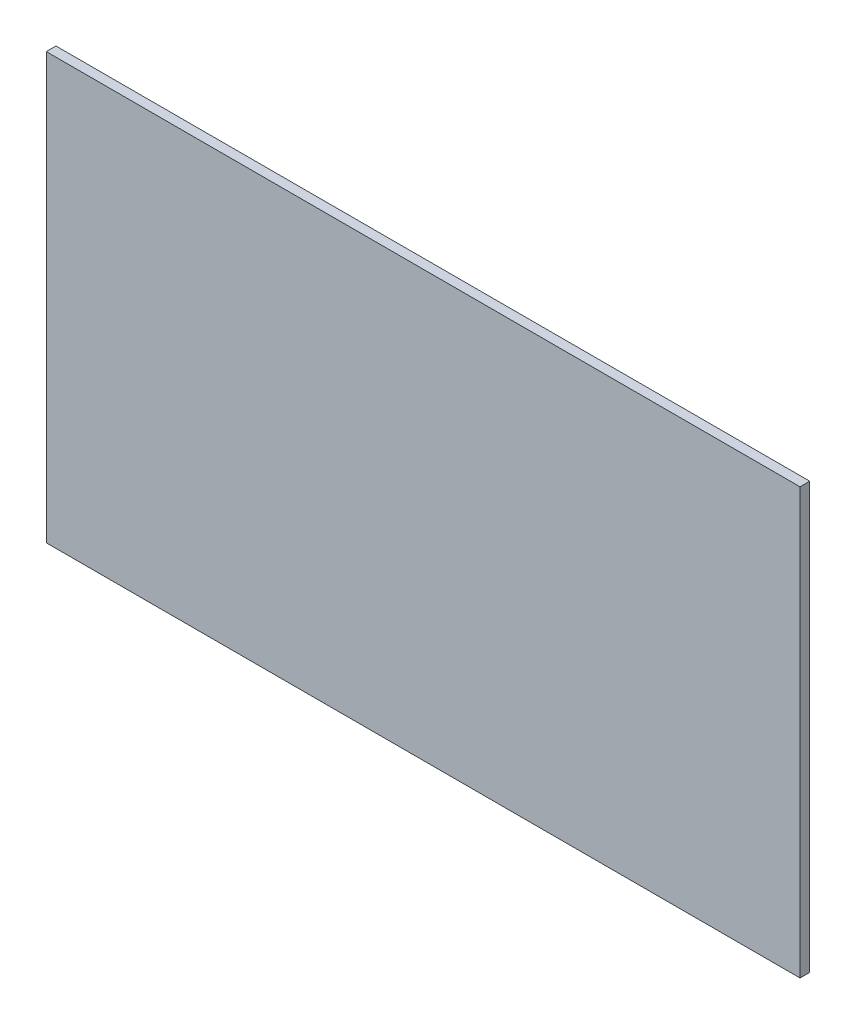
from build123d import *

# Parameters (mm, degrees)
SKETCH1_W           = 233
SKETCH1_H           = 131.5
BOSS_EXTRUDE1_DEPTH = 3


with BuildPart() as part:
    # Sketch1 → Boss-Extrude1 (new body)
    with BuildSketch(Plane.XY):
        with Locations((116.5, -65.75)):
            Rectangle(SKETCH1_W, SKETCH1_H)
    extrude(amount=BOSS_EXTRUDE1_DEPTH)


solid = part.part
